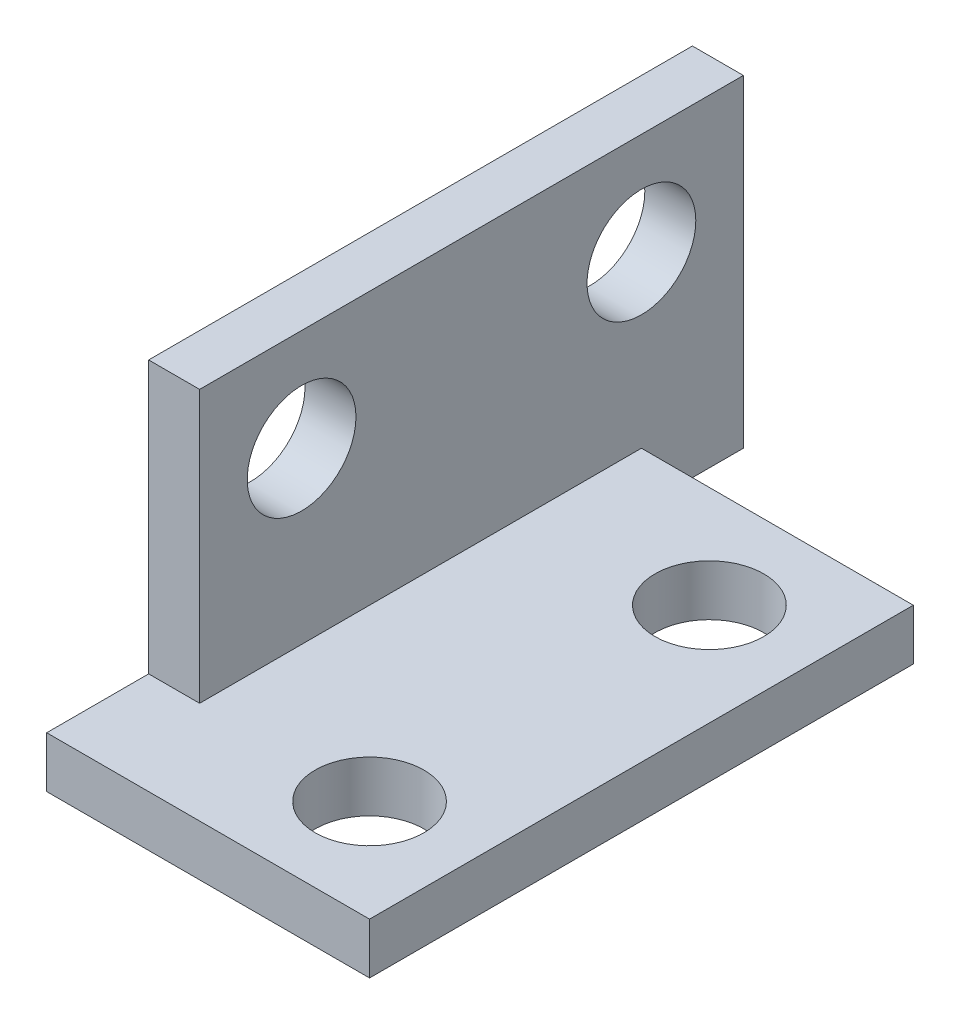
from build123d import *

# Parameters (mm, degrees)
SKETCH1_R           = 1.6
BOSS_EXTRUDE2_DEPTH = 1.5
SKETCH3_W           = 1.5
SKETCH3_H           = 21
BOSS_EXTRUDE3_DEPTH = 8
SKETCH4_R           = 1.6
CUT_EXTRUDE2_DEPTH  = 8
SKETCH6_W           = 5
SKETCH6_H           = 8
CUT_EXTRUDE3_DEPTH  = 8
SKETCH7_W           = 8
SKETCH7_H           = 5
CUT_EXTRUDE4_DEPTH  = 8
SKETCH8_R           = 46.480094089
CUT_EXTRUDE5_DEPTH  = 64
SKETCH9_W           = 5
SKETCH9_H           = 8
CUT_EXTRUDE6_DEPTH  = 64
SKETCH10_W          = 8
SKETCH10_H          = 5
CUT_EXTRUDE7_DEPTH  = 64
SKETCH11_R          = 1.6
CUT_EXTRUDE8_DEPTH  = 1.5
BOSS_EXTRUDE5_DEPTH = 1.5
SKETCH13_W          = 2
SKETCH13_H          = 9.5
CUT_EXTRUDE9_DEPTH  = 1.5


with BuildPart() as part:
    # Sketch1 → Boss-Extrude2 (new body)
    with BuildSketch(Plane(origin=(0, 0, 0), x_dir=(1, 0, 0), z_dir=(0, 1, 0))):
        Polygon((-3, 8), (-3, -13), (0, -13), (6.5, -13), (6.5, 0), (6.5, 8), (0, 8), align=None)
        with Locations(Location((0, 0, 0), (0, 0, 270))):
            Circle(SKETCH1_R, mode=Mode.SUBTRACT)
        with Locations(Location((0, -10, 0), (0, 0, 270))):
            Circle(SKETCH1_R, mode=Mode.SUBTRACT)
    boss_extrude2 = extrude(amount=BOSS_EXTRUDE2_DEPTH)

    # Sketch3 → Boss-Extrude3 (add)
    with BuildSketch(Plane(origin=(0, 1.5, 0), x_dir=(1, 0, 0), z_dir=(0, 1, 0))):
        with Locations((5.75, -2.5)):
            Rectangle(SKETCH3_W, SKETCH3_H)
    boss_extrude3 = extrude(amount=BOSS_EXTRUDE3_DEPTH)

    # Sketch4 → Cut-Extrude2 (cut)
    with BuildSketch(Plane.ZY.offset(-5)):
        with Locations((-5, 6.5)):
            Circle(SKETCH4_R)
        with Locations((5, 6.5)):
            Circle(SKETCH4_R)
    cut_extrude2 = extrude(amount=-CUT_EXTRUDE2_DEPTH, mode=Mode.SUBTRACT)

    # Sketch6 → Cut-Extrude3 (cut)
    with BuildSketch(Plane.ZY.offset(-5)):
        with Locations((10.5, 5.5)):
            Rectangle(SKETCH6_W, SKETCH6_H)
    extrude(amount=-CUT_EXTRUDE3_DEPTH, mode=Mode.SUBTRACT)

    # Sketch7 → Cut-Extrude4 (cut)
    with BuildSketch(Plane(origin=(0, 1.5, 0), x_dir=(1, 0, 0), z_dir=(0, 1, 0))):
        with Locations((1, 5.5)):
            Rectangle(SKETCH7_W, SKETCH7_H)
    extrude(amount=-CUT_EXTRUDE4_DEPTH, mode=Mode.SUBTRACT)

    # Mirror1: Boss-Extrude2, Boss-Extrude3, Cut-Extrude2 across plane
    add(boss_extrude2.mirror(Plane(origin=(6.5, 1.5, 0), x_dir=(0, 0, 1), z_dir=(-1, 0, 0))))
    add(boss_extrude3.mirror(Plane(origin=(6.5, 1.5, 0), x_dir=(0, 0, 1), z_dir=(-1, 0, 0))))
    add(cut_extrude2.mirror(Plane(origin=(6.5, 1.5, 0), x_dir=(0, 0, 1), z_dir=(-1, 0, 0))), mode=Mode.SUBTRACT)

    # Sketch8 → Cut-Extrude5 (cut)
    with BuildSketch(Plane.ZY.offset(-6.5)):
        with Locations((8, 1.5)):
            Circle(SKETCH8_R)
    extrude(amount=CUT_EXTRUDE5_DEPTH, mode=Mode.SUBTRACT)

    # Sketch9 → Cut-Extrude6 (cut)
    with BuildSketch(Plane(origin=(8, 0, 0), x_dir=(0, 0, -1), z_dir=(1, 0, 0))):
        with Locations((-10.5, 5.5)):
            Rectangle(SKETCH9_W, SKETCH9_H)
    extrude(amount=-CUT_EXTRUDE6_DEPTH, mode=Mode.SUBTRACT)

    # Sketch10 → Cut-Extrude7 (cut)
    with BuildSketch(Plane(origin=(0, 1.5, 0), x_dir=(1, 0, 0), z_dir=(0, 1, 0))):
        with Locations((12, 5.5)):
            Rectangle(SKETCH10_W, SKETCH10_H)
    extrude(amount=-CUT_EXTRUDE7_DEPTH, mode=Mode.SUBTRACT)

    # Sketch11 → Cut-Extrude8 (cut)
    with BuildSketch(Plane(origin=(8, 0, 0), x_dir=(0, 0, -1), z_dir=(1, 0, 0))):
        with Locations((-7, 6.5)):
            Circle(SKETCH11_R)
        with Locations((3, 6.5)):
            Circle(SKETCH11_R)
    extrude(amount=-CUT_EXTRUDE8_DEPTH, mode=Mode.SUBTRACT)

    # Sketch12 → Boss-Extrude5 (add)
    with BuildSketch(Plane(origin=(8, 0, 0), x_dir=(0, 0, -1), z_dir=(1, 0, 0))):
        with BuildLine():
            Line((-10, 1.5), (-8, 1.5))
            Line((-8, 1.5), (-8, 5.2510004))
            ThreePointArc((-8, 5.2510004), (-8.6, 6.5), (-8, 7.7489996))
            Line((-8, 7.7489996), (-8, 9.5))
            Line((-8, 9.5), (-10, 9.5))
            Line((-10, 9.5), (-10, 6.5))
            Line((-10, 6.5), (-10, 1.5))
        make_face()
        with BuildLine():
            ThreePointArc((-5.4, 6.5), (-5.55777949, 5.807179677), (-6, 5.2510004))
            ThreePointArc((-6, 5.2510004), (-3.4, 6.5), (-6, 7.7489996))
            ThreePointArc((-6, 7.7489996), (-5.55777949, 7.192820323), (-5.4, 6.5))
        make_face()
        with BuildLine():
            ThreePointArc((-6, 7.7489996), (-3.4, 6.5), (-6, 5.2510004))
            ThreePointArc((-6, 5.2510004), (-7, 4.9), (-8, 5.2510004))
            Line((-8, 5.2510004), (-8, 1.5))
            Line((-8, 1.5), (3, 1.5))
            Line((3, 1.5), (3, 0))
            Line((3, 0), (8, 0))
            Line((8, 0), (8, 9.5))
            Line((8, 9.5), (-8, 9.5))
            Line((-8, 9.5), (-8, 7.7489996))
            ThreePointArc((-8, 7.7489996), (-7, 8.1), (-6, 7.7489996))
        make_face()
        with BuildLine():
            ThreePointArc((4, 7.7489996), (6.6, 6.5), (4, 5.2510004))
            ThreePointArc((4, 5.2510004), (1.4, 6.5), (4, 7.7489996))
        make_face(mode=Mode.SUBTRACT)
        with BuildLine():
            ThreePointArc((4, 5.2510004), (4.6, 6.5), (4, 7.7489996))
            ThreePointArc((4, 7.7489996), (6.6, 6.5), (4, 5.2510004))
        make_face()
    extrude(amount=-BOSS_EXTRUDE5_DEPTH)

    # Sketch13 → Cut-Extrude9 (cut)
    with BuildSketch(Plane(origin=(8, 0, 0), x_dir=(0, 0, -1), z_dir=(1, 0, 0))):
        with Locations((7, 4.75)):
            Rectangle(SKETCH13_W, SKETCH13_H)
    extrude(amount=-CUT_EXTRUDE9_DEPTH, mode=Mode.SUBTRACT)


solid = part.part
